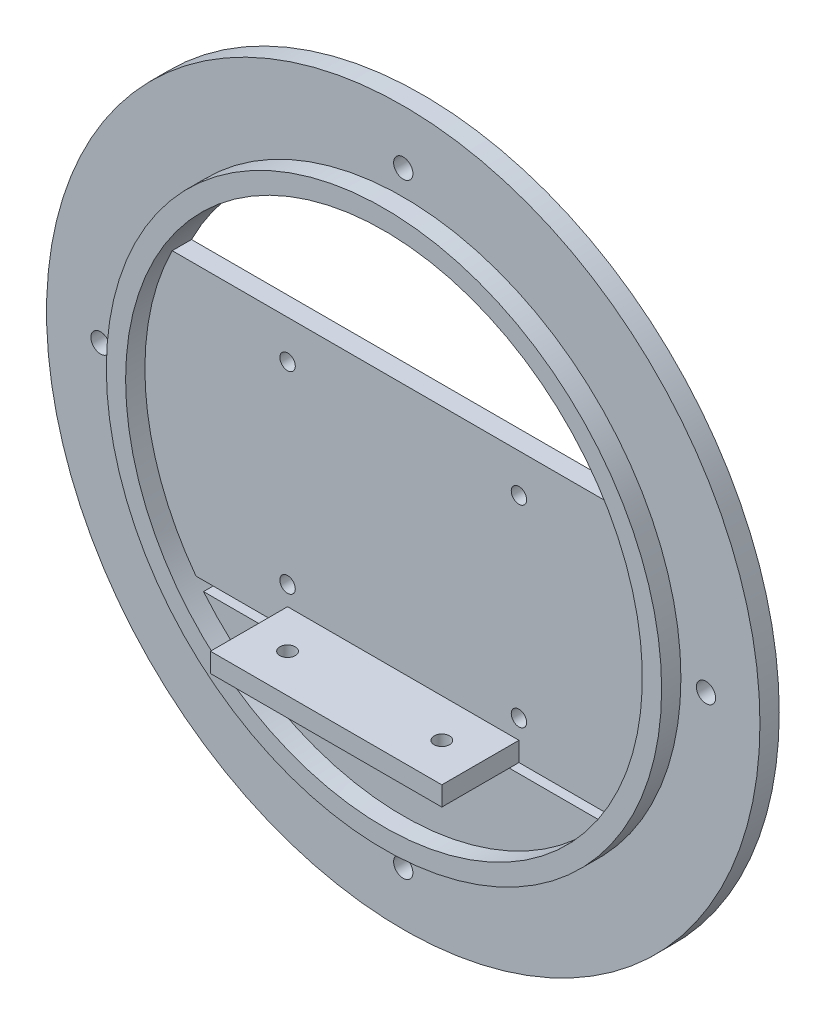
from build123d import *

# Parameters (mm, degrees)
SKETCH1_R           = 92.5
BOSS_EXTRUDE1_DEPTH = 5
SKETCH2_R           = 72
BOSS_EXTRUDE2_DEPTH = 5
SKETCH3_R           = 67
CUT_EXTRUDE1_DEPTH  = 11
SKETCH4_W           = 140
SKETCH4_H           = 70
BOSS_EXTRUDE3_DEPTH = 5
SKETCH6_W           = 60
SKETCH6_H           = 5
BOSS_EXTRUDE4_DEPTH = 20
FILLET1_R           = 2.5
SKETCH7_W           = 110
SKETCH7_H           = 25
BOSS_EXTRUDE5_DEPTH = 5
SKETCH8_W           = 60
SKETCH8_H           = 5
BOSS_EXTRUDE6_DEPTH = 30
SKETCH9_R           = 2
CUT_EXTRUDE2_DEPTH  = 5
SKETCH10_R          = 2
CUT_EXTRUDE3_DEPTH  = 5
SKETCH11_R          = 2
CUT_EXTRUDE4_DEPTH  = 5
SKETCH12_R          = 2.5
CUT_EXTRUDE5_DEPTH  = 5


with BuildPart() as part:
    # Sketch1 → Boss-Extrude1 (new body)
    with BuildSketch(Plane.XY):
        Circle(SKETCH1_R)
    extrude(amount=BOSS_EXTRUDE1_DEPTH)

    # Sketch2 → Boss-Extrude2 (add)
    with BuildSketch(Plane.XY.offset(5)):
        Circle(SKETCH2_R)
    extrude(amount=BOSS_EXTRUDE2_DEPTH)

    # Sketch3 → Cut-Extrude1 (cut, through all)
    with BuildSketch(Plane(origin=(0, 0, 0), x_dir=(-1, 0, 0), z_dir=(0, 0, -1))):
        Circle(SKETCH3_R)
    extrude(amount=-CUT_EXTRUDE1_DEPTH, mode=Mode.SUBTRACT)

    # Sketch4 → Boss-Extrude3 (add)
    with BuildSketch(Plane(origin=(0, 0, 0), x_dir=(-1, 0, 0), z_dir=(0, 0, -1))):
        with Locations((0, -5)):
            Rectangle(SKETCH4_W, SKETCH4_H)
    extrude(amount=-BOSS_EXTRUDE3_DEPTH)

    # Sketch6 → Boss-Extrude4 (add)
    with BuildSketch(Plane.XY.offset(5)):
        with Locations((0, -37.5)):
            Rectangle(SKETCH6_W, SKETCH6_H)
    extrude(amount=BOSS_EXTRUDE4_DEPTH)

    # Fillet1
    fillet1_edges = [part.edges().sort_by_distance(p)[0] for p in [
        (0, -40, 0),
    ]]
    fillet(fillet1_edges, radius=FILLET1_R)

    # Sketch7 → Boss-Extrude5 (add)
    with BuildSketch(Plane(origin=(0, 0, 0), x_dir=(-1, 0, 0), z_dir=(0, 0, -1))):
        with Locations((0, -55)):
            Rectangle(SKETCH7_W, SKETCH7_H)
    extrude(amount=-BOSS_EXTRUDE5_DEPTH)

    # Sketch8 → Boss-Extrude6 (add)
    with BuildSketch(Plane(origin=(0, 0, 0), x_dir=(-1, 0, 0), z_dir=(0, 0, -1))):
        with Locations((0, -45)):
            Rectangle(SKETCH8_W, SKETCH8_H)
    extrude(amount=BOSS_EXTRUDE6_DEPTH)

    # Sketch9 → Cut-Extrude2 (cut)
    with BuildSketch(Plane(origin=(0, -35, 0), x_dir=(1, 0, 0), z_dir=(0, 1, 0))):
        with Locations((-20, -15)):
            Circle(SKETCH9_R)
        with Locations((20, -15)):
            Circle(SKETCH9_R)
    extrude(amount=-CUT_EXTRUDE2_DEPTH, mode=Mode.SUBTRACT)

    # Sketch10 → Cut-Extrude3 (cut)
    with BuildSketch(Plane(origin=(0, -42.5, 0), x_dir=(1, 0, 0), z_dir=(0, 1, 0))):
        with Locations((-20, 20)):
            Circle(SKETCH10_R)
        with Locations((20, 20)):
            Circle(SKETCH10_R)
    extrude(amount=-CUT_EXTRUDE3_DEPTH, mode=Mode.SUBTRACT)

    # Sketch11 → Cut-Extrude4 (cut)
    with BuildSketch(Plane(origin=(0, 0, 0), x_dir=(-1, 0, 0), z_dir=(0, 0, -1))):
        with Locations((-30, -30)):
            Circle(SKETCH11_R)
        with Locations((-30, 20)):
            Circle(SKETCH11_R)
        with Locations((30, 20)):
            Circle(SKETCH11_R)
        with Locations((30, -30)):
            Circle(SKETCH11_R)
    extrude(amount=-CUT_EXTRUDE4_DEPTH, mode=Mode.SUBTRACT)

    # Sketch12 → Cut-Extrude5 (cut)
    with BuildSketch(Plane(origin=(0, 0, 0), x_dir=(-1, 0, 0), z_dir=(0, 0, -1))):
        with Locations((0, -78.5)):
            Circle(SKETCH12_R)
        with Locations((-78.5, 0)):
            Circle(SKETCH12_R)
        with Locations((0, 78.5)):
            Circle(SKETCH12_R)
        with Locations((78.5, 0)):
            Circle(SKETCH12_R)
    extrude(amount=-CUT_EXTRUDE5_DEPTH, mode=Mode.SUBTRACT)


solid = part.part
